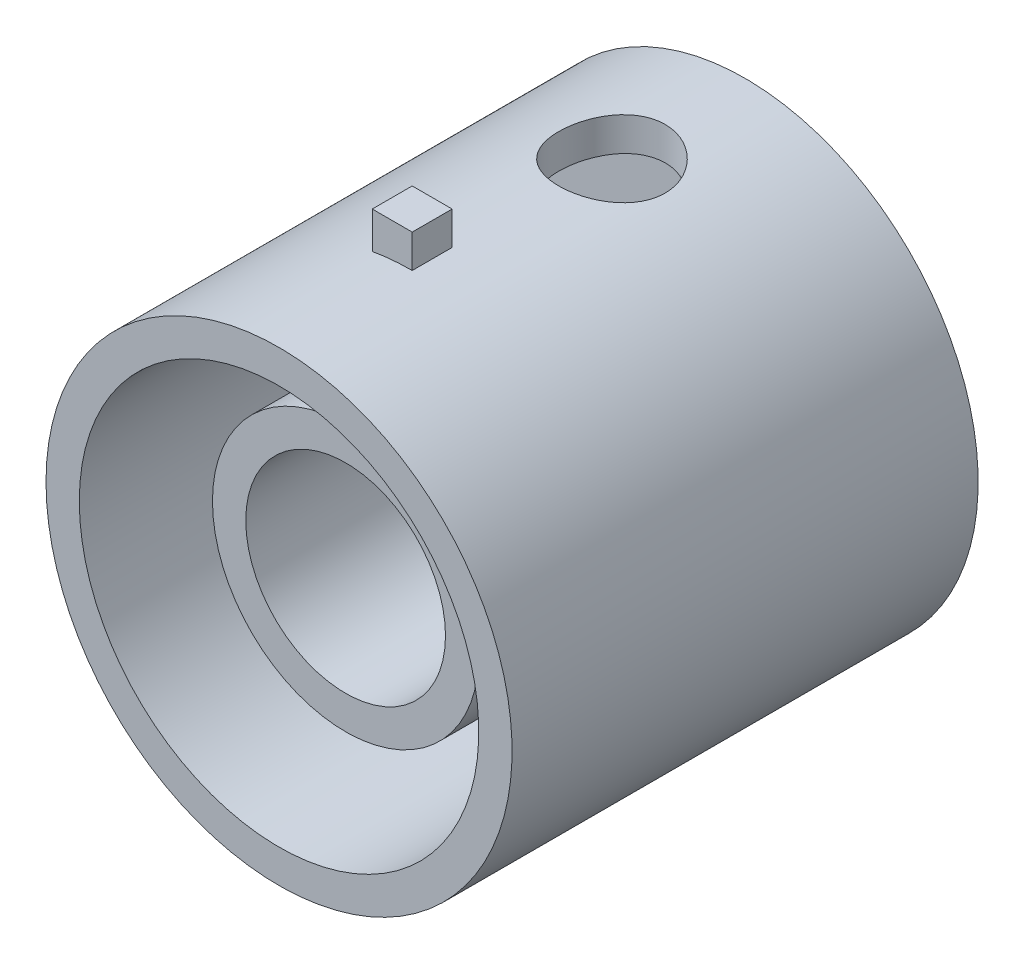
from build123d import *

# Parameters (mm, degrees)
SKETCH3_W           = 3
SKETCH3_H           = 5
BOSS_EXTRUDE1_DEPTH = 3
SKETCH5_R           = 4
CUT_EXTRUDE1_DEPTH  = 5


with BuildPart() as part:
    # Sketch1 → Revolve1 (revolve)
    with BuildSketch(Plane.XZ):
        Polygon((7.5, 5), (0, 5), (0, 3), (15, 3), (15, 0), (17.5, 0), (17.5, 35), (15, 35), (15, 5), (10, 5), (10, 30), (7.5, 30), align=None)
    revolve(axis=Axis((0, 0, 35), (0, 0, -1)))

    # Sketch3 → Boss-Extrude1 (add)
    with BuildSketch(Plane.XY.offset(25)):
        with Locations((-1.5, 17.5)):
            Rectangle(SKETCH3_W, SKETCH3_H)
        with Locations((-1.5, -17.5)):
            Rectangle(SKETCH3_W, SKETCH3_H)
    extrude(amount=-BOSS_EXTRUDE1_DEPTH)

    # Sketch5 → Cut-Extrude1 (cut)
    with BuildSketch(Plane(origin=(0, 13, 0), x_dir=(1, 0, 0), z_dir=(0, 1, 0))):
        with Locations((0, -10)):
            Circle(SKETCH5_R)
    extrude(amount=CUT_EXTRUDE1_DEPTH, mode=Mode.SUBTRACT)


solid = part.part
